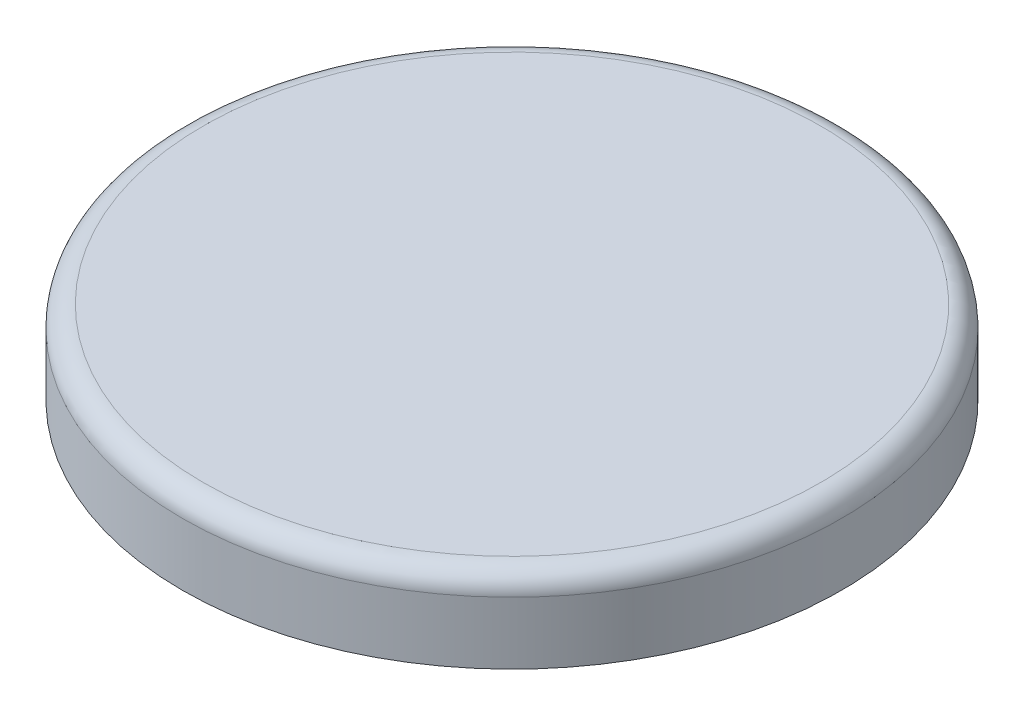
from build123d import *

# Parameters (mm, degrees)
SKETCH1_R           = 3.175
BOSS_EXTRUDE1_DEPTH = 0.8
FILLET3_R           = 0.2


with BuildPart() as part:
    # Sketch1 → Boss-Extrude1 (new body)
    with BuildSketch(Plane(origin=(0, 0, 0), x_dir=(1, 0, 0), z_dir=(0, 1, 0))):
        Circle(SKETCH1_R)
    extrude(amount=BOSS_EXTRUDE1_DEPTH)

    # Fillet3
    fillet3_edges = [part.edges().sort_by_distance(p)[0] for p in [
        (-3.175, 0.8, 0),
    ]]
    fillet(fillet3_edges, radius=FILLET3_R)


solid = part.part
